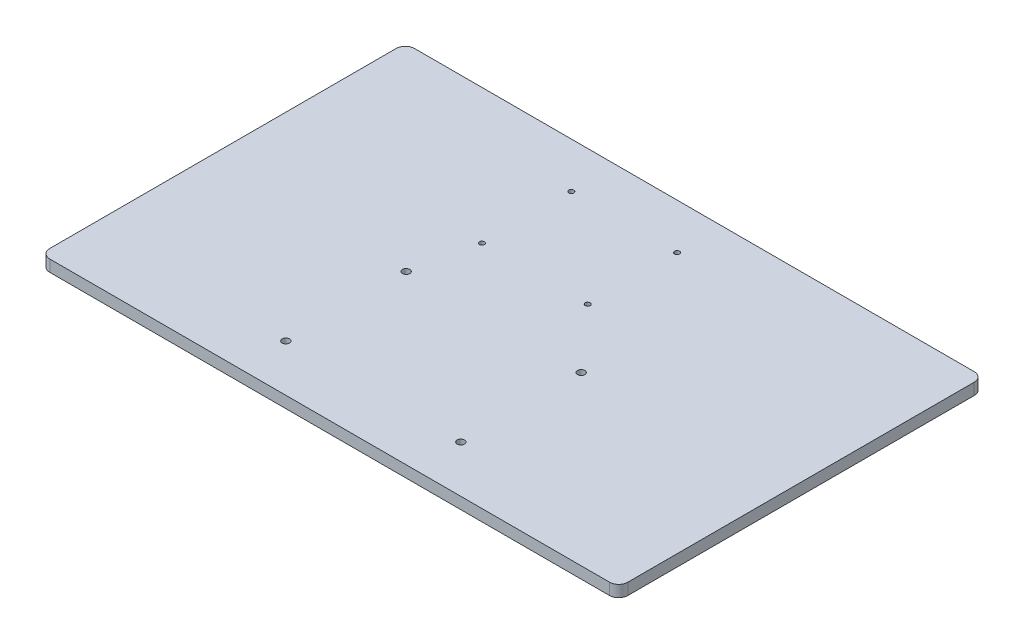
from build123d import *

# Parameters (mm, degrees)
SKETCH1_W           = 317
SKETCH1_H           = 200
BOSS_EXTRUDE1_DEPTH = 6.35
FILLET1_R           = 5
SKETCH2_R           = 2
SKETCH2_R_2         = 1.375
CUT_EXTRUDE1_DEPTH  = 10


with BuildPart() as part:
    # Sketch1 → Boss-Extrude1 (new body)
    with BuildSketch(Plane(origin=(0, 0, 0), x_dir=(1, 0, 0), z_dir=(0, 1, 0))):
        Rectangle(SKETCH1_W, SKETCH1_H)
    extrude(amount=-BOSS_EXTRUDE1_DEPTH)

    # Fillet1
    fillet1_edges = [part.edges().sort_by_distance(p)[0] for p in [
        (-158.5, -3.175, -100),
        (158.5, -3.175, -100),
        (158.5, -3.175, 100),
        (-158.5, -3.175, 100),
    ]]
    fillet(fillet1_edges, radius=FILLET1_R)

    # Sketch2 → Cut-Extrude1 (cut)
    with BuildSketch(Plane(origin=(93.325, 0, -211.68), x_dir=(0, 0, -1), z_dir=(0, 1, 0))):
        with Locations((-219.881035079, 47.177621018)):
            Circle(SKETCH2_R)
        with Locations((-285.881035079, 47.177621018)):
            Circle(SKETCH2_R)
        with Locations((-219.881035079, 143.177621018)):
            Circle(SKETCH2_R)
        with Locations((-285.881035079, 143.177621018)):
            Circle(SKETCH2_R)
        with Locations((-136.648177626, 77.839658286)):
            Circle(SKETCH2_R_2)
        with Locations((-185.648177626, 77.839658286)):
            Circle(SKETCH2_R_2)
        with Locations((-185.648177626, 135.839658286)):
            Circle(SKETCH2_R_2)
        with Locations((-136.648177626, 135.839658286)):
            Circle(SKETCH2_R_2)
    extrude(amount=-CUT_EXTRUDE1_DEPTH, mode=Mode.SUBTRACT)


solid = part.part
